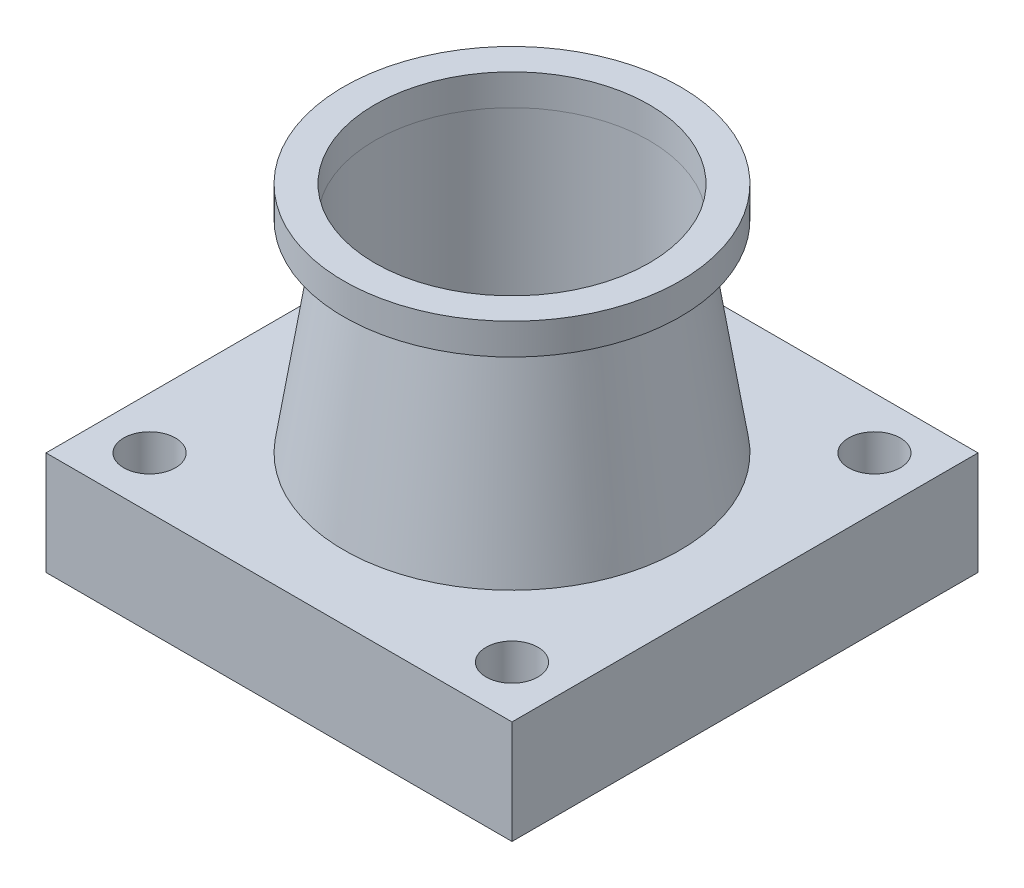
from build123d import *

# Parameters (mm, degrees)
SKETCH1_W           = 90
SKETCH1_H           = 90
BOSS_EXTRUDE1_DEPTH = 20
SKETCH3_R           = 26.5
CUT_EXTRUDE1_DEPTH  = 45
SKETCH4_R           = 5
CUT_EXTRUDE2_DEPTH  = 21


with BuildPart() as part:
    # Sketch1 → Boss-Extrude1 (new body)
    with BuildSketch(Plane(origin=(0, 0, 0), x_dir=(1, 0, 0), z_dir=(0, 1, 0))):
        Rectangle(SKETCH1_W, SKETCH1_H)
    extrude(amount=BOSS_EXTRUDE1_DEPTH)

    # Sketch2 → Revolve1 (revolve)
    with BuildSketch(Plane(origin=(0, 0, 0), x_dir=(0, 0, -1), z_dir=(1, 0, 0))):
        Polygon((0, 20), (0, 65), (32.5, 65), (32.5, 59), (26.5, 59), (32.5, 20), align=None)
    revolve(axis=Axis((0, 20, 0), (0, 1, 0)))

    # Sketch3 → Cut-Extrude1 (cut)
    with BuildSketch(Plane(origin=(0, 65, 0), x_dir=(1, 0, 0), z_dir=(0, 1, 0))):
        Circle(SKETCH3_R)
    extrude(amount=-CUT_EXTRUDE1_DEPTH, mode=Mode.SUBTRACT)

    # Sketch4 → Cut-Extrude2 (cut, through all)
    with BuildSketch(Plane(origin=(0, 20, 0), x_dir=(1, 0, 0), z_dir=(0, 1, 0))):
        with Locations((-35, -35)):
            Circle(SKETCH4_R)
        with Locations((35, -35)):
            Circle(SKETCH4_R)
        with Locations((35, 35)):
            Circle(SKETCH4_R)
        with Locations((-35, 35)):
            Circle(SKETCH4_R)
    extrude(amount=-CUT_EXTRUDE2_DEPTH, mode=Mode.SUBTRACT)


solid = part.part
